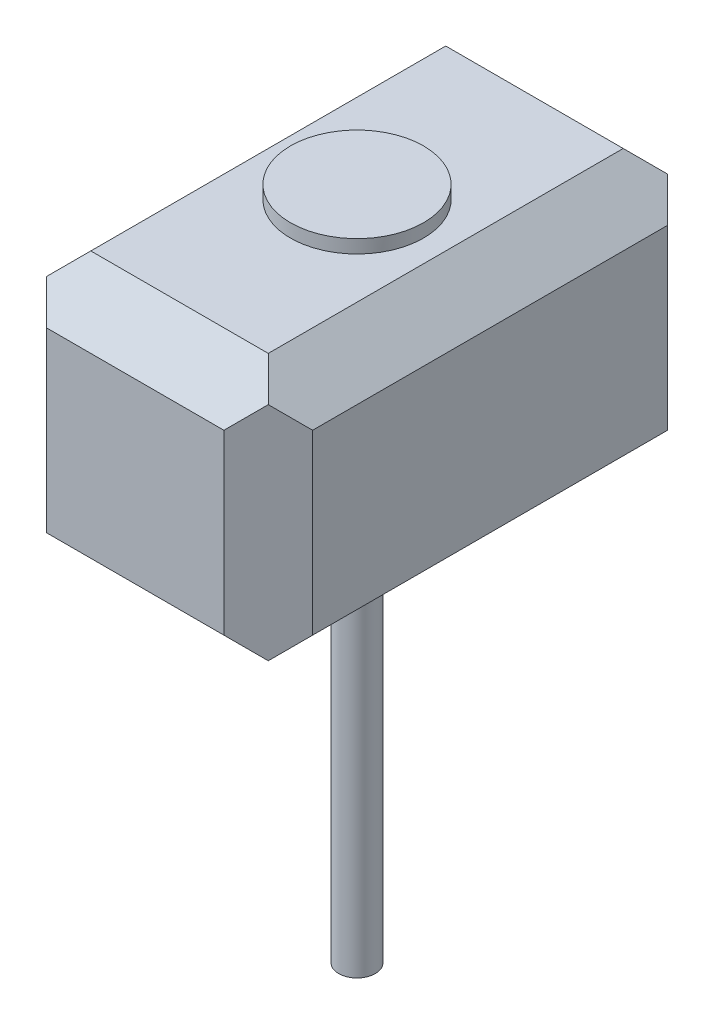
from build123d import *

# Parameters (mm, degrees)
SKETCH_1_W      = 60
SKETCH_1_H      = 60
EXTRUDE_1_DEPTH = 100
CHAMFER_1_SIZE  = 10
CHAMFER_2_SIZE  = 10
CHAMFER_3_SIZE  = 10
CHAMFER_4_SIZE  = 10
CHAMFER_5_SIZE  = 10
CHAMFER_6_SIZE  = 10
CHAMFER_7_SIZE  = 10
CHAMFER_8_SIZE  = 10
SKETCH_4_R      = 15
EXTRUDE_2_DEPTH = 3
SKETCH_5_R      = 4.130427407
EXTRUDE_3_DEPTH = 89
CHAMFER_9_SIZE  = 10
CHAMFER_10_SIZE = 10
CHAMFER_11_SIZE = 10


with BuildPart() as part:
    # 草图1 → 凸台-拉伸1 (new body)
    with BuildSketch(Plane.XY):
        Rectangle(SKETCH_1_W, SKETCH_1_H)
    extrude(amount=EXTRUDE_1_DEPTH)

    # 倒角1
    chamfer_1_edges = [part.edges().sort_by_distance(p)[0] for p in [
        (0, 30, 0),
    ]]
    chamfer(chamfer_1_edges, length=CHAMFER_1_SIZE)

    # 倒角2
    chamfer_2_edges = [part.edges().sort_by_distance(p)[0] for p in [
        (-30, -5, 0),
    ]]
    chamfer(chamfer_2_edges, length=CHAMFER_2_SIZE)

    # 倒角3
    chamfer_3_edges = [part.edges().sort_by_distance(p)[0] for p in [
        (5, -30, 0),
    ]]
    chamfer(chamfer_3_edges, length=CHAMFER_3_SIZE)

    # 倒角4
    chamfer_4_edges = [part.edges().sort_by_distance(p)[0] for p in [
        (30, 0, 0),
    ]]
    chamfer(chamfer_4_edges, length=CHAMFER_4_SIZE)

    # 倒角5
    chamfer_5_edges = [part.edges().sort_by_distance(p)[0] for p in [
        (0, 30, 100),
    ]]
    chamfer(chamfer_5_edges, length=CHAMFER_5_SIZE)

    # 倒角6
    chamfer_6_edges = [part.edges().sort_by_distance(p)[0] for p in [
        (30, -5, 100),
    ]]
    chamfer(chamfer_6_edges, length=CHAMFER_6_SIZE)

    # 倒角7
    chamfer_7_edges = [part.edges().sort_by_distance(p)[0] for p in [
        (-30, -5, 100),
    ]]
    chamfer(chamfer_7_edges, length=CHAMFER_7_SIZE)

    # 倒角8
    chamfer_8_edges = [part.edges().sort_by_distance(p)[0] for p in [
        (0, -30, 100),
    ]]
    chamfer(chamfer_8_edges, length=CHAMFER_8_SIZE)

    # 草图4 → 凸台-拉伸2 (add)
    with BuildSketch(Plane(origin=(0, 30, 0), x_dir=(1, 0, 0), z_dir=(0, 1, 0))):
        with Locations(Location((0, -50, 0), (0, 0, 90))):  # turned: the seam where the file's is
            Circle(SKETCH_4_R)
    extrude(amount=EXTRUDE_2_DEPTH)

    # 草图5 → 凸台-拉伸3 (add)
    with BuildSketch(Plane.XZ.offset(30)):
        with Locations(Location((0, 50, 0), (0, 0, 90))):  # turned: the seam where the file's is
            Circle(SKETCH_5_R)
    extrude(amount=EXTRUDE_3_DEPTH)

    # 倒角9
    chamfer_9_edges = [part.edges().sort_by_distance(p)[0] for p in [
        (30, 30, 50),
    ]]
    chamfer(chamfer_9_edges, length=CHAMFER_9_SIZE)

    # 倒角10
    chamfer_10_edges = [part.edges().sort_by_distance(p)[0] for p in [
        (-30, 30, 50),
    ]]
    chamfer(chamfer_10_edges, length=CHAMFER_10_SIZE)

    # 倒角11
    chamfer_11_edges = [part.edges().sort_by_distance(p)[0] for p in [
        (30, -30, 50),
    ]]
    chamfer(chamfer_11_edges, length=CHAMFER_11_SIZE)


solid = part.part
